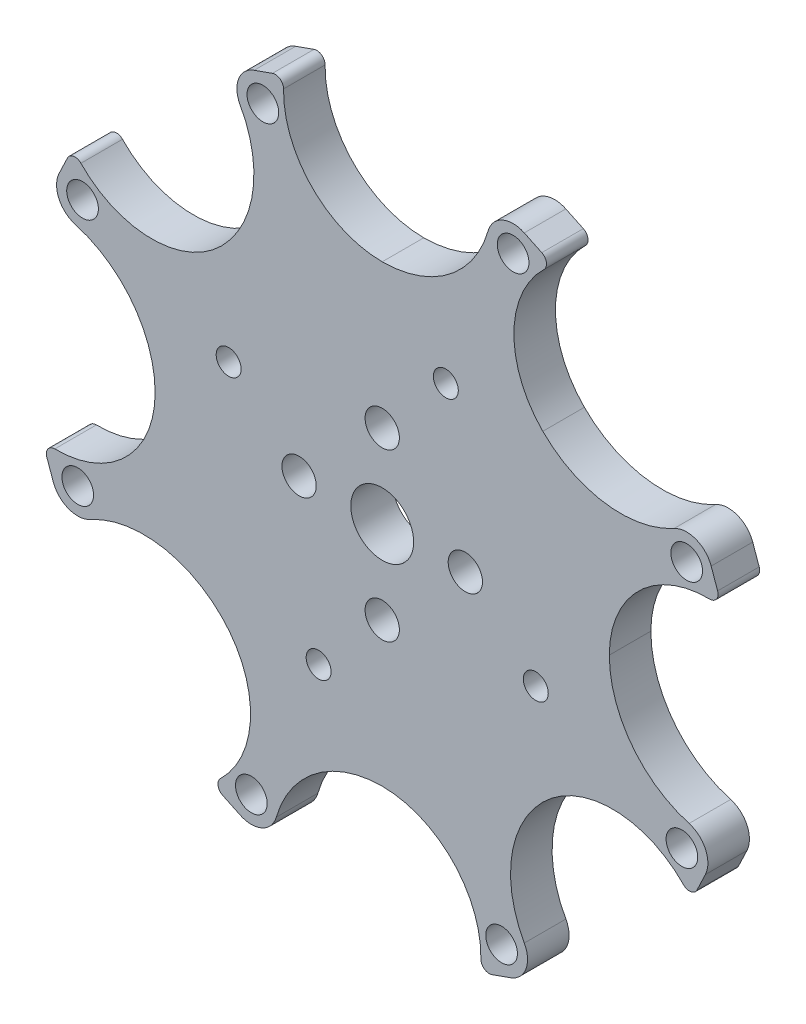
from build123d import *

# Parameters (mm, degrees)
SKETCH_1_R          = 1.525
SKETCH_1_R_2        = 3.025
SKETCH_1_R_3        = 1.65
EXTRUDE_1_DEPTH     = 4
SKETCH_2_R          = 1.2
CUT_EXTRUDE_1_DEPTH = 10


with BuildPart() as part:
    # 草图1 → 凸台-拉伸1 (new body)
    with BuildSketch(Plane.XY):
        with BuildLine():
            Line((15.356969673, 30.298929166), (13.674015522, 31.101791788))
            ThreePointArc((13.674015522, 31.101791788), (11.571454033, 31.125101256), (10.194791162, 29.535727958))
            ThreePointArc((10.194791162, 29.535727958), (6.381394442, 23.991783581), (0, 21.857511157))
            ThreePointArc((0, 21.857511157), (-6.773355282, 24.696305694), (-9.498676044, 31.516109427))
            ThreePointArc((-9.498676044, 31.516109427), (-9.831389744, 32.178886119), (-10.565560882, 32.28359567))
            Line((-10.565560882, 32.28359567), (-12.323298779, 31.661276982))
            ThreePointArc((-12.323298779, 31.661276982), (-13.826516548, 30.191023779), (-13.676107562, 28.09371949))
            ThreePointArc((-13.676107562, 28.09371949), (-12.45242558, 21.477080146), (-15.455594359, 15.455594359))
            ThreePointArc((-15.455594359, 15.455594359), (-22.252410678, 12.673439775), (-29.001832935, 15.568676449))
            ThreePointArc((-29.001832935, 15.568676449), (-29.705750942, 15.802066229), (-30.298929166, 15.356969673))
            Line((-30.298929166, 15.356969673), (-31.101791788, 13.674015522))
            ThreePointArc((-31.101791788, 13.674015522), (-31.125101256, 11.571454033), (-29.535727958, 10.194791162))
            ThreePointArc((-29.535727958, 10.194791162), (-23.991783581, 6.381394442), (-21.857511157, 0))
            ThreePointArc((-21.857511157, 0), (-24.696305694, -6.773355282), (-31.516109427, -9.498676044))
            ThreePointArc((-31.516109427, -9.498676044), (-32.178886119, -9.831389744), (-32.28359567, -10.565560882))
            Line((-32.28359567, -10.565560882), (-31.661276982, -12.323298779))
            ThreePointArc((-31.661276982, -12.323298779), (-30.191023779, -13.826516548), (-28.09371949, -13.676107562))
            ThreePointArc((-28.09371949, -13.676107562), (-21.477080146, -12.45242558), (-15.455594359, -15.455594359))
            ThreePointArc((-15.455594359, -15.455594359), (-12.673439775, -22.252410678), (-15.568676449, -29.001832935))
            ThreePointArc((-15.568676449, -29.001832935), (-15.802066229, -29.705750942), (-15.356969673, -30.298929166))
            Line((-15.356969673, -30.298929166), (-13.674015522, -31.101791788))
            ThreePointArc((-13.674015522, -31.101791788), (-11.571454033, -31.125101256), (-10.194791162, -29.535727958))
            ThreePointArc((-10.194791162, -29.535727958), (-6.381394442, -23.991783581), (0, -21.857511157))
            ThreePointArc((0, -21.857511157), (6.773355282, -24.696305694), (9.498676044, -31.516109427))
            ThreePointArc((9.498676044, -31.516109427), (9.831389744, -32.178886119), (10.565560882, -32.28359567))
            Line((10.565560882, -32.28359567), (12.323298779, -31.661276982))
            ThreePointArc((12.323298779, -31.661276982), (13.826516548, -30.191023779), (13.676107562, -28.09371949))
            ThreePointArc((13.676107562, -28.09371949), (12.45242558, -21.477080146), (15.455594359, -15.455594359))
            ThreePointArc((15.455594359, -15.455594359), (22.252410678, -12.673439775), (29.001832935, -15.568676449))
            ThreePointArc((29.001832935, -15.568676449), (29.705750942, -15.802066229), (30.298929166, -15.356969673))
            Line((30.298929166, -15.356969673), (31.101791788, -13.674015522))
            ThreePointArc((31.101791788, -13.674015522), (31.125101256, -11.571454033), (29.535727958, -10.194791162))
            ThreePointArc((29.535727958, -10.194791162), (23.991783581, -6.381394442), (21.857511157, 0))
            ThreePointArc((21.857511157, 0), (24.696305694, 6.773355282), (31.516109427, 9.498676044))
            ThreePointArc((31.516109427, 9.498676044), (32.178886119, 9.831389744), (32.28359567, 10.565560882))
            Line((32.28359567, 10.565560882), (31.661276982, 12.323298779))
            ThreePointArc((31.661276982, 12.323298779), (30.191023779, 13.826516548), (28.09371949, 13.676107562))
            ThreePointArc((28.09371949, 13.676107562), (21.477080146, 12.45242558), (15.455594359, 15.455594359))
            ThreePointArc((15.455594359, 15.455594359), (12.673439775, 22.252410678), (15.568676449, 29.001832935))
            ThreePointArc((15.568676449, 29.001832935), (15.802066229, 29.705750942), (15.356969673, 30.298929166))
        make_face()
        with Locations((12.597590691, 28.845398741)):
            Circle(SKETCH_1_R, mode=Mode.SUBTRACT)
        with Locations((29.304618859, 11.488935252)):
            Circle(SKETCH_1_R, mode=Mode.SUBTRACT)
        with Locations((28.845398741, -12.597590691)):
            Circle(SKETCH_1_R, mode=Mode.SUBTRACT)
        with Locations((11.488935252, -29.304618859)):
            Circle(SKETCH_1_R, mode=Mode.SUBTRACT)
        with Locations((-12.597590691, -28.845398741)):
            Circle(SKETCH_1_R, mode=Mode.SUBTRACT)
        with Locations((-29.304618859, -11.488935252)):
            Circle(SKETCH_1_R, mode=Mode.SUBTRACT)
        with Locations((-28.845398741, 12.597590691)):
            Circle(SKETCH_1_R, mode=Mode.SUBTRACT)
        with Locations((-11.488935252, 29.304618859)):
            Circle(SKETCH_1_R, mode=Mode.SUBTRACT)
        Circle(SKETCH_1_R_2, mode=Mode.SUBTRACT)
        with Locations((-8, 0)):
            Circle(SKETCH_1_R_3, mode=Mode.SUBTRACT)
        with Locations((0, 8)):
            Circle(SKETCH_1_R_3, mode=Mode.SUBTRACT)
        with Locations((8, 0)):
            Circle(SKETCH_1_R_3, mode=Mode.SUBTRACT)
        with Locations((0, -8)):
            Circle(SKETCH_1_R_3, mode=Mode.SUBTRACT)
    extrude(amount=EXTRUDE_1_DEPTH)

    # 草图2 → 切除-拉伸1 (cut)
    with BuildSketch(Plane.XY.offset(4)):
        with Locations((-6.122934918, -14.78207252)):
            Circle(SKETCH_2_R)
        with Locations((-14.78207252, 6.122934918)):
            Circle(SKETCH_2_R)
        with Locations((6.122934918, 14.78207252)):
            Circle(SKETCH_2_R)
        with Locations((14.78207252, -6.122934918)):
            Circle(SKETCH_2_R)
    extrude(amount=-CUT_EXTRUDE_1_DEPTH, mode=Mode.SUBTRACT)


solid = part.part
